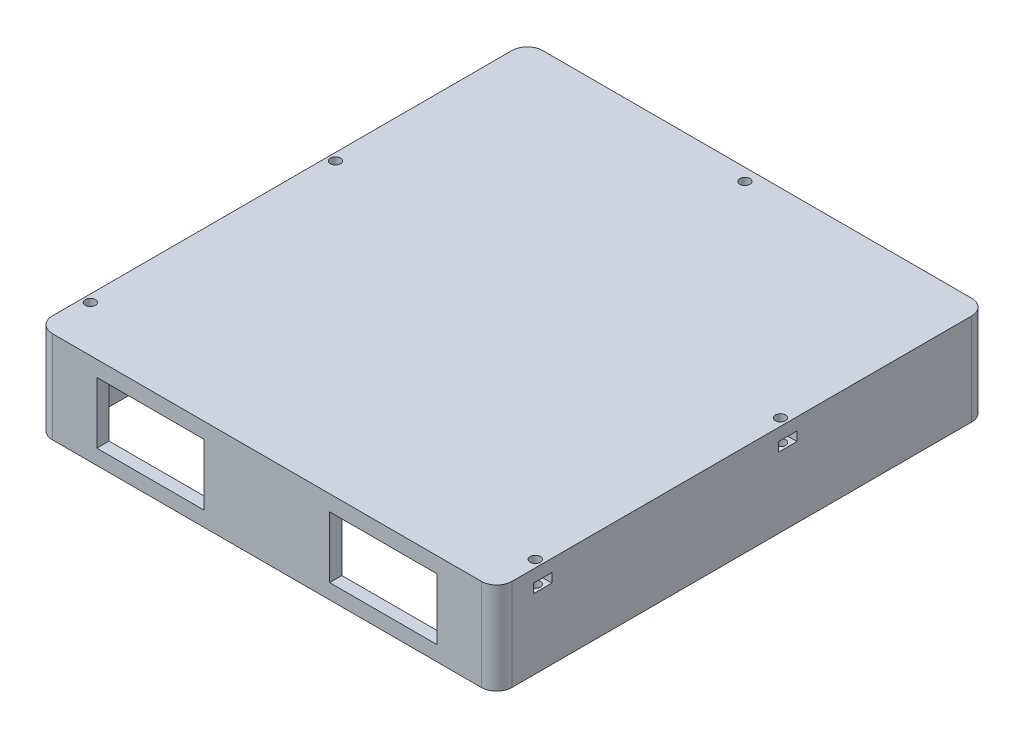
from build123d import *

# Parameters (mm, degrees)
SKETCH_1_W           = 150
SKETCH_1_H           = 160
EXTRUDE_1_DEPTH      = 30
FILLET_1_R           = 5
SKETCH_3_W           = 140
SKETCH_3_H           = 152
CUT_EXTRUDE_2_DEPTH  = 26
SKETCH_9_W           = 6
SKETCH_9_H           = 3
CUT_EXTRUDE_7_DEPTH  = 151
FILLET_2_R           = 2
SKETCH_11_R          = 1.65
CUT_EXTRUDE_8_DEPTH  = 8
SKETCH_12_W          = 6.5
SKETCH_12_H          = 3.3
CUT_EXTRUDE_9_DEPTH  = 15
SKETCH_16_W          = 35
SKETCH_16_H          = 20
CUT_EXTRUDE_12_DEPTH = 40
SKETCH_17_R          = 1.65
CUT_EXTRUDE_13_DEPTH = 10


with BuildPart() as part:
    # 草图1 → 凸台-拉伸1 (new body)
    with BuildSketch(Plane(origin=(0, 0, 0), x_dir=(1, 0, 0), z_dir=(0, 1, 0))):
        Rectangle(SKETCH_1_W, SKETCH_1_H)
    extrude(amount=EXTRUDE_1_DEPTH)

    # 圆角1
    fillet_1_edges = [part.edges().sort_by_distance(p)[0] for p in [
        (75, 15, 80),
        (-75, 15, 80),
        (-75, 15, -80),
        (75, 15, -80),
    ]]
    fillet(fillet_1_edges, radius=FILLET_1_R)

    # 草图3 → 切除-拉伸2 (cut)
    with BuildSketch(Plane.XZ):
        Rectangle(SKETCH_3_W, SKETCH_3_H)
    extrude(amount=-CUT_EXTRUDE_2_DEPTH, mode=Mode.SUBTRACT)

    # 草图9 → 切除-拉伸7 (cut, through all)
    with BuildSketch(Plane.ZY.offset(75)):
        with Locations((65, 24.5)):
            Rectangle(SKETCH_9_W, SKETCH_9_H)
        with Locations((-15, 24.5)):
            Rectangle(SKETCH_9_W, SKETCH_9_H)
    extrude(amount=-CUT_EXTRUDE_7_DEPTH, mode=Mode.SUBTRACT)

    # 圆角2
    fillet_2_edges = [part.edges().sort_by_distance(p)[0] for p in [
        (-70, 13, -76),
        (-70, 13, 76),
        (70, 13, 76),
        (70, 13, -76),
    ]]
    fillet(fillet_2_edges, radius=FILLET_2_R)

    # 草图11 → 切除-拉伸8 (cut)
    with BuildSketch(Plane(origin=(0, 30, 0), x_dir=(1, 0, 0), z_dir=(0, 1, 0))):
        with Locations((0, 76)):
            Circle(SKETCH_11_R)
    extrude(amount=-CUT_EXTRUDE_8_DEPTH, mode=Mode.SUBTRACT)

    # 草图12 → 切除-拉伸9 (cut)
    with BuildSketch(Plane(origin=(0, 0, -80), x_dir=(-1, 0, 0), z_dir=(0, 0, -1))):
        with Locations((0, 23.35)):
            Rectangle(SKETCH_12_W, SKETCH_12_H)
    extrude(amount=-CUT_EXTRUDE_9_DEPTH, mode=Mode.SUBTRACT)

    # 草图16 → 切除-拉伸12 (cut)
    with BuildSketch(Plane.XY.offset(80)):
        with Locations((37.995108753, 14.88178475)):
            Rectangle(SKETCH_16_W, SKETCH_16_H)
        with Locations((-37.995108753, 14.88178475)):
            Rectangle(SKETCH_16_W, SKETCH_16_H)
    extrude(amount=-CUT_EXTRUDE_12_DEPTH, mode=Mode.SUBTRACT)

    # 草图17 → 切除-拉伸13 (cut)
    with BuildSketch(Plane(origin=(0, 30, 0), x_dir=(1, 0, 0), z_dir=(0, 1, 0))):
        with Locations((-72.6, -65)):
            Circle(SKETCH_17_R)
        with Locations((72.6, -65)):
            Circle(SKETCH_17_R)
        with Locations((-72.6, 15)):
            Circle(SKETCH_17_R)
        with Locations((72.6, 15)):
            Circle(SKETCH_17_R)
    extrude(amount=-CUT_EXTRUDE_13_DEPTH, mode=Mode.SUBTRACT)


solid = part.part
